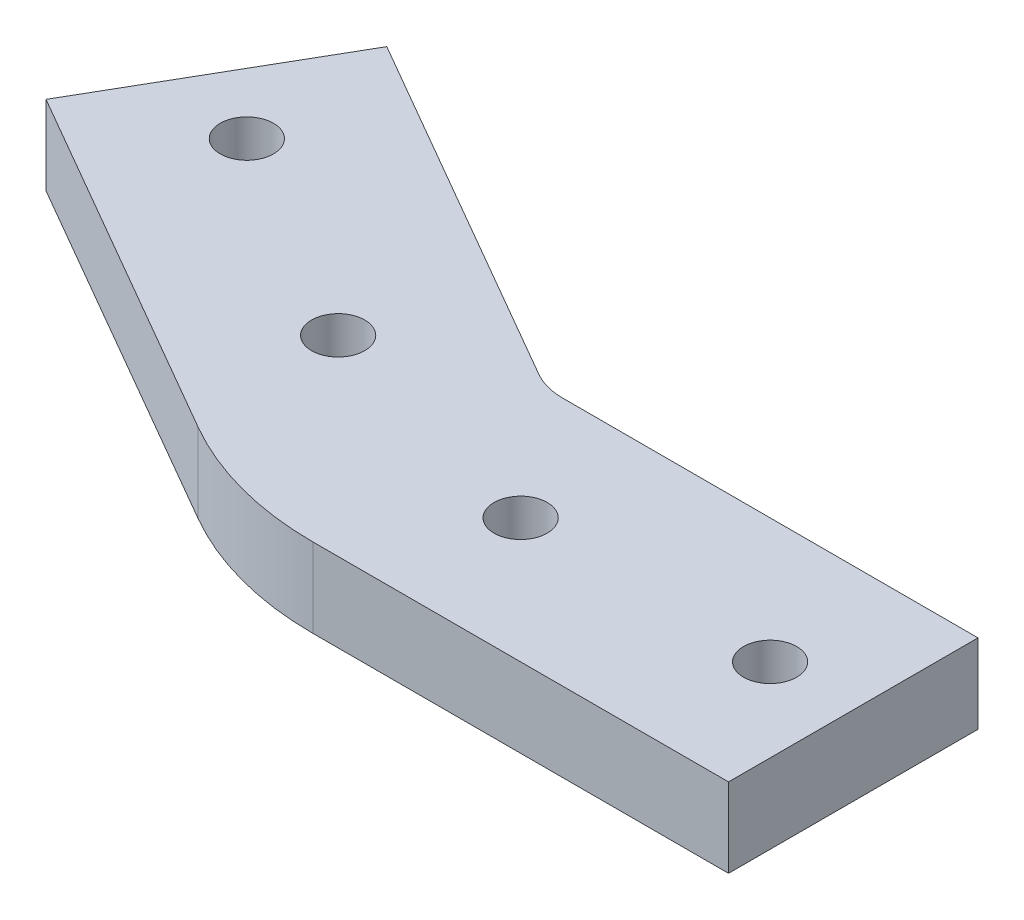
from build123d import *

# Parameters (mm, degrees)
SKETCH1_R           = 1.6
BOSS_EXTRUDE1_DEPTH = 4.7625


with BuildPart() as part:
    # Sketch1 → Boss-Extrude1 (new body)
    with BuildSketch(Plane(origin=(0, 0, 0), x_dir=(1, 0, 0), z_dir=(0, 1, 0))):
        with BuildLine():
            Line((28.033109467, 7.5), (28.033109467, -7.5))
            Line((28.033109467, -7.5), (3.033109467, -7.5))
            ThreePointArc((3.033109467, -7.5), (-1.837792139, -6.858733638), (-6.376749851, -4.978635795))
            Line((-6.376749851, -4.978635795), (-28.027384945, 7.521364205))
            Line((-28.027384945, 7.521364205), (-20.527384945, 20.511745262))
            Line((-20.527384945, 20.511745262), (1.123250149, 8.011745262))
            ThreePointArc((1.123250149, 8.011745262), (2.044493537, 7.630153756), (3.033109467, 7.5))
            Line((3.033109467, 7.5), (28.033109467, 7.5))
        make_face()
        with Locations((23.033109467, 0)):
            Circle(SKETCH1_R, mode=Mode.SUBTRACT)
        with Locations((8.033109467, 0)):
            Circle(SKETCH1_R, mode=Mode.SUBTRACT)
        with Locations((-19.947257926, 11.516554733)):
            Circle(SKETCH1_R, mode=Mode.SUBTRACT)
        with Locations((-6.956876869, 4.016554733)):
            Circle(SKETCH1_R, mode=Mode.SUBTRACT)
    extrude(amount=BOSS_EXTRUDE1_DEPTH)


solid = part.part
